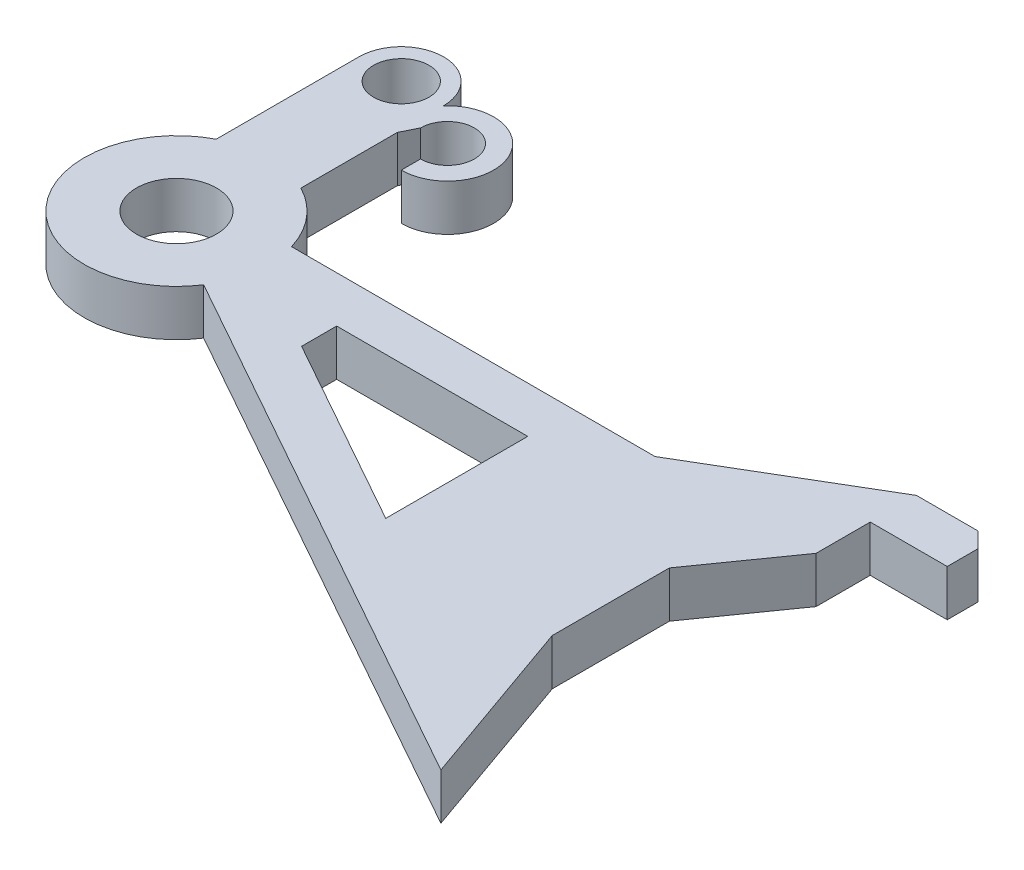
from build123d import *

# Parameters (mm, degrees)
SKETCH_2_R          = 6
SKETCH_2_R_2        = 2.6
EXTRUDE_1_DEPTH     = 3
SKETCH_3_R          = 1.8
EXTRUDE_2_DEPTH     = 3
EXTRUDE_3_DEPTH     = 3
EXTRUDE_4_DEPTH     = 3
CHAMFER_2_SIZE      = 1
CUT_EXTRUDE_1_DEPTH = 5


with BuildPart() as part:
    # 草图2 → 凸台-拉伸1 (new body)
    with BuildSketch(Plane(origin=(0, 0, 0), x_dir=(1, 0, 0), z_dir=(0, 1, 0))):
        Circle(SKETCH_2_R)
        Circle(SKETCH_2_R_2, mode=Mode.SUBTRACT)
    extrude(amount=EXTRUDE_1_DEPTH)

    # 草图3 → 凸台-拉伸2 (add)
    with BuildSketch(Plane(origin=(0, 3, 0), x_dir=(1, 0, 0), z_dir=(0, 1, 0))):
        with BuildLine():
            Line((-2.75, 14.603353962), (-2.75, 5.332682252))
            Line((-2.75, 5.332682252), (2.75, 5.332682252))
            Line((2.75, 5.332682252), (2.75, 14.603353962))
            ThreePointArc((2.75, 14.603353962), (0, 17.353353962), (-2.75, 14.603353962))
        make_face()
        with Locations((0, 14.603353962)):
            Circle(SKETCH_3_R, mode=Mode.SUBTRACT)
    extrude(amount=-EXTRUDE_2_DEPTH)

    # 草图5 → 凸台-拉伸3 (add)
    with BuildSketch(Plane(origin=(0, 3, 0), x_dir=(1, 0, 0), z_dir=(0, 1, 0))):
        with BuildLine():
            Line((3.25, 12.603353962), (2.458972536, 11.008619055))
            ThreePointArc((2.458972536, 11.008619055), (6.451860062, 15.228635349), (5, 9.603353962))
            Line((5, 9.603353962), (5, 10.853353962))
            ThreePointArc((5, 10.853353962), (6.237436867, 13.840790829), (3.25, 12.603353962))
        make_face()
    extrude(amount=-EXTRUDE_3_DEPTH)

    # 草图6 → 凸台-拉伸4 (add)
    with BuildSketch(Plane(origin=(0, 3, 0), x_dir=(1, 0, 0), z_dir=(0, 1, 0))):
        Polygon((5.032823561, -3.266601752), (40.031302406, -22.854160513), (36.087762843, -11.678430785), (36.087762843, -4.064639853), (40.031302406, 1.52127196), (40.031302406, 5.037888577), (45.031302406, 5.037888577), (45.031302406, 8.037888577), (40.031302406, 8.037888577), (29.357105905, 1.733398248), (5.032823561, 1.733398248), align=None)
    extrude(amount=-EXTRUDE_4_DEPTH)

    # 倒角2
    chamfer_2_edges = [part.edges().sort_by_distance(p)[0] for p in [
        (45.031302406, 1.5, -8.037888577),
    ]]
    chamfer(chamfer_2_edges, length=CHAMFER_2_SIZE)

    # 草图7 → 切除-拉伸1 (cut, symmetric)
    with BuildSketch(Plane(origin=(0, 3, 0), x_dir=(1, 0, 0), z_dir=(0, 1, 0))):
        Polygon((11.673818528, -3.545473406), (24.087762843, -10.49317147), (24.087762843, -1.266601752), (11.673818528, -1.266601752), align=None)
    extrude(amount=CUT_EXTRUDE_1_DEPTH, both=True, mode=Mode.SUBTRACT)


solid = part.part
